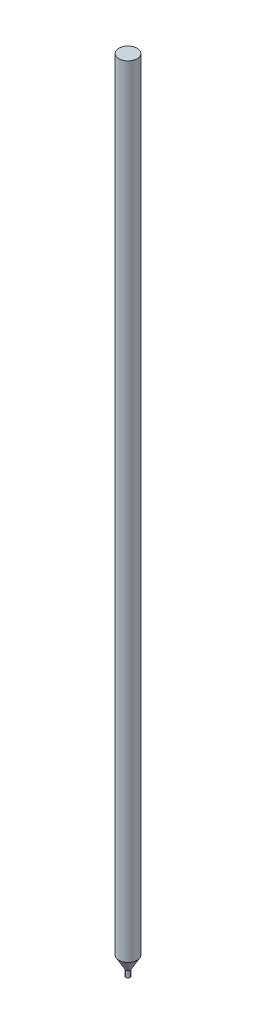
from build123d import *

# Parameters (mm, degrees)
SKETCH1_R           = 0.875
BOSS_EXTRUDE1_DEPTH = 75


with BuildPart() as part:
    # Sketch1 → Boss-Extrude1 (new body)
    with BuildSketch(Plane(origin=(0, 0, 0), x_dir=(1, 0, 0), z_dir=(0, 1, 0))):
        Circle(SKETCH1_R)
    extrude(amount=BOSS_EXTRUDE1_DEPTH)

    # Sketch2 → Revolve1 (revolve)
    with BuildSketch(Plane(origin=(0, 0, 0), x_dir=(0, 0, -1), z_dir=(1, 0, 0))):
        Polygon((0, 0), (0, -1.769134295), (0.2, -1.769134295), (0.2, -1.169134295), (0.875, 0), align=None)
    revolve(axis=Axis((0, 0, 0), (0, -1, 0)))


solid = part.part
